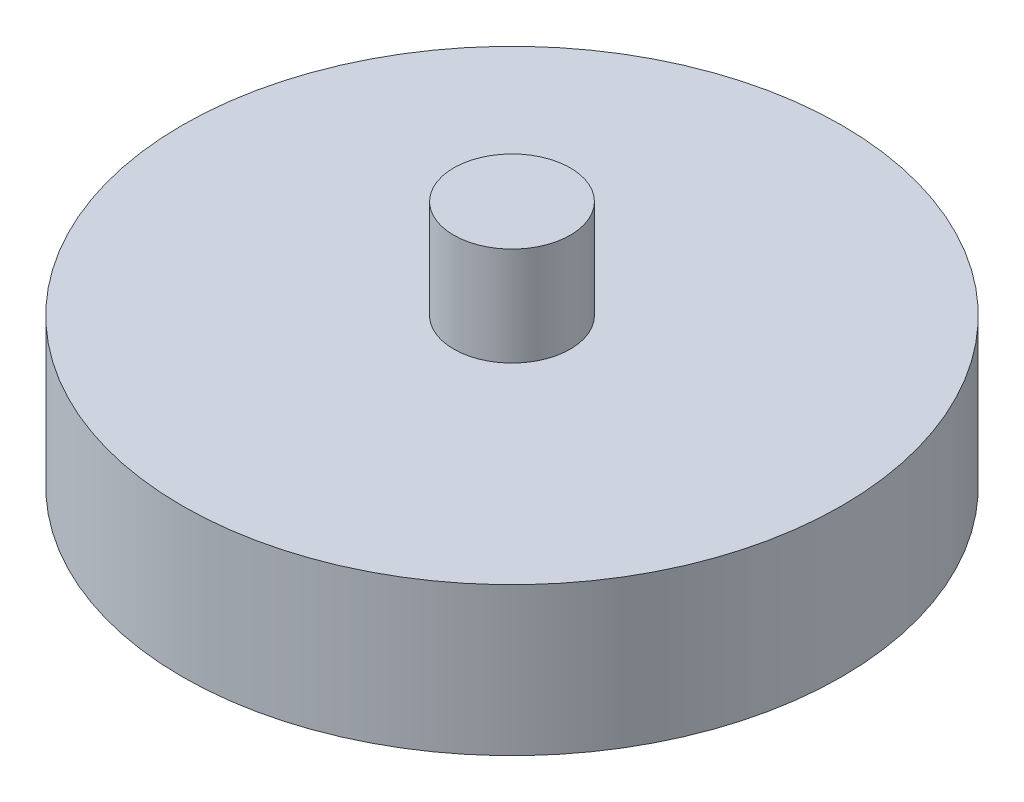
from build123d import *

# Parameters (mm, degrees)
SKETCH2_R           = 33.932535707
BOSS_EXTRUDE1_DEPTH = 15.24
SKETCH3_R           = 6
BOSS_EXTRUDE2_DEPTH = 25.4
SKETCH4_R           = 25.4
CUT_EXTRUDE1_DEPTH  = 2.54


with BuildPart() as part:
    # Sketch2 → Boss-Extrude1 (new body)
    with BuildSketch(Plane(origin=(0, 0, 0), x_dir=(1, 0, 0), z_dir=(0, 1, 0))):
        Circle(SKETCH2_R)
    extrude(amount=BOSS_EXTRUDE1_DEPTH)

    # Sketch3 → Boss-Extrude2 (add)
    with BuildSketch(Plane(origin=(0, 0, 0), x_dir=(1, 0, 0), z_dir=(0, 1, 0))):
        Circle(SKETCH3_R)
    extrude(amount=BOSS_EXTRUDE2_DEPTH)

    # Sketch4 → Cut-Extrude1 (cut)
    with BuildSketch(Plane.XZ):
        Circle(SKETCH4_R)
    extrude(amount=-CUT_EXTRUDE1_DEPTH, mode=Mode.SUBTRACT)


solid = part.part
